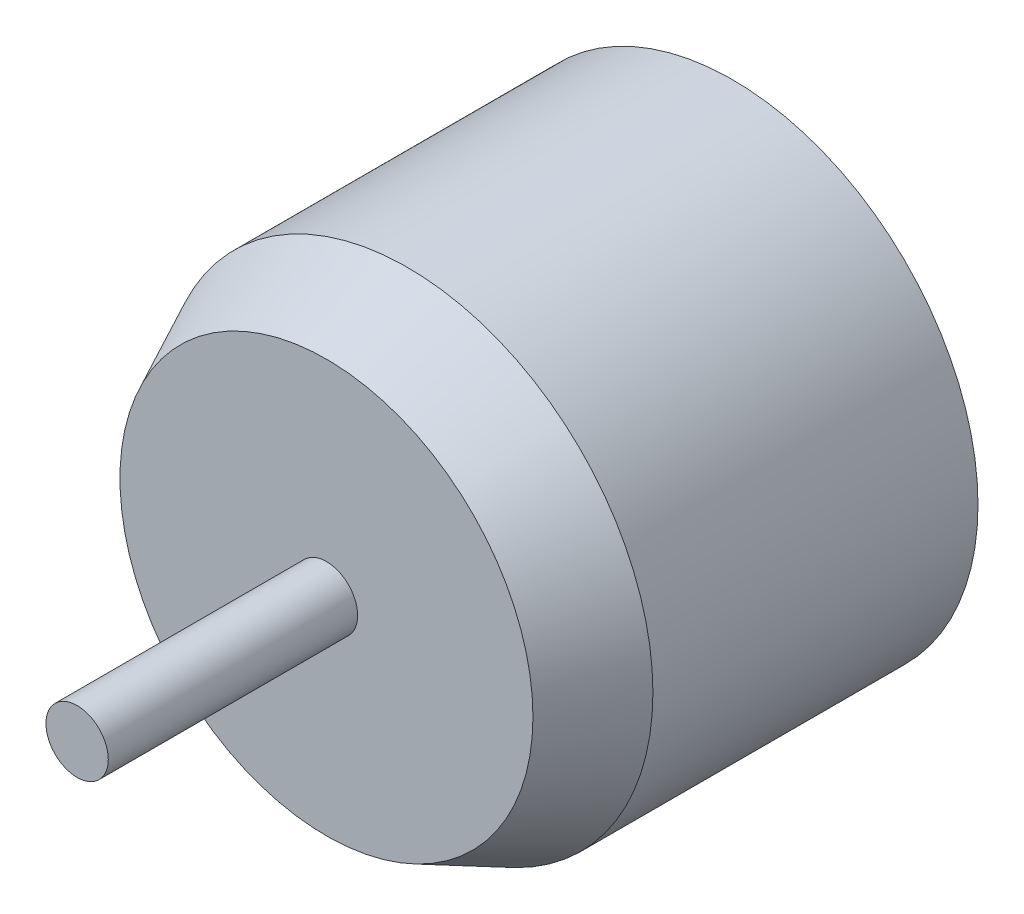
from build123d import *


with BuildPart() as part:
    # Sketch1 → Revolve1 (revolve)
    with BuildSketch(Plane(origin=(0, 0, 0), x_dir=(0, 0, -1), z_dir=(1, 0, 0))):
        Polygon((-102.752853447, 0), (-15.752853447, 0), (-15.752853447, 22.291570592), (-18.63982365, 31.5), (-60.358717431, 31.5), (-70.752853447, 26.498463611), (-70.752853447, 4), (-102.752853447, 4), align=None)
    revolve(axis=Axis((0, 0, 164.609375), (0, 0, -1)))


solid = part.part
